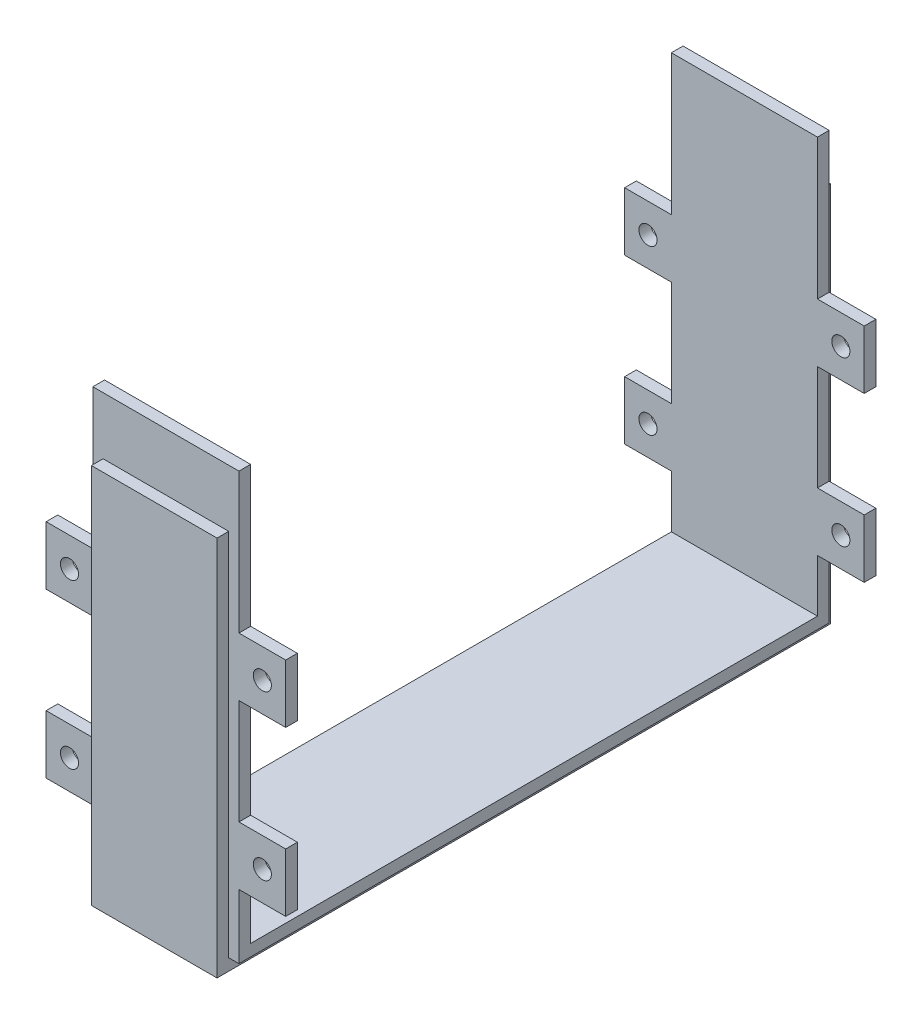
from build123d import *

# Parameters (mm, degrees)
SKETCH1_W           = 105
SKETCH1_H           = 4
SKETCH1_W_2         = 2
SKETCH1_H_2         = 9.8
BOSS_EXTRUDE1_DEPTH = 12.5
SKETCH2_W           = 8
SKETCH2_H           = 10
SKETCH2_R           = 1.55
BOSS_EXTRUDE2_DEPTH = 2
SKETCH4_W           = 8
SKETCH4_H           = 10
SKETCH4_R           = 1.55
BOSS_EXTRUDE3_DEPTH = 2
SKETCH5_W           = 101
SKETCH5_H           = 2
CUT_EXTRUDE1_DEPTH  = 1.75
SKETCH6_W           = 101
SKETCH6_H           = 2
CUT_EXTRUDE2_DEPTH  = 1.75


with BuildPart() as part:
    # Sketch1 → Boss-Extrude1 (new body, symmetric)
    with BuildSketch(Plane(origin=(0, 0, 0), x_dir=(0, 0, -1), z_dir=(1, 0, 0))):
        Rectangle(SKETCH1_W, SKETCH1_H)
        Polygon((-52.5, 63.2), (-52.5, 2), (-48.5, 2), (-48.5, 63.2), (-50.5, 63.2), align=None)
        Polygon((48.5, 63.2), (48.5, 2), (52.5, 2), (52.5, 63.2), (50.5, 63.2), align=None)
        with Locations((-49.5, 68.1)):
            Rectangle(SKETCH1_W_2, SKETCH1_H_2)
        with Locations((49.5, 68.1)):
            Rectangle(SKETCH1_W_2, SKETCH1_H_2)
    extrude(amount=BOSS_EXTRUDE1_DEPTH, both=True)

    # Sketch2 → Boss-Extrude2 (add)
    with BuildSketch(Plane.XY.offset(-48.5)):
        with Locations((-16.5, 16)):
            Rectangle(SKETCH2_W, SKETCH2_H)
        with Locations((-16.5, 16)):
            Circle(SKETCH2_R, mode=Mode.SUBTRACT)
        with Locations((-16.5, 44)):
            Rectangle(SKETCH2_W, SKETCH2_H)
        with Locations((-16.5, 44)):
            Circle(SKETCH2_R, mode=Mode.SUBTRACT)
        with Locations((16.5, 16)):
            Rectangle(SKETCH2_W, SKETCH2_H)
        with Locations((16.5, 16)):
            Circle(SKETCH2_R, mode=Mode.SUBTRACT)
        with Locations((16.5, 44)):
            Rectangle(SKETCH2_W, SKETCH2_H)
        with Locations((16.5, 44)):
            Circle(SKETCH2_R, mode=Mode.SUBTRACT)
    extrude(amount=-BOSS_EXTRUDE2_DEPTH)

    # Sketch4 → Boss-Extrude3 (add)
    with BuildSketch(Plane(origin=(0, 0, 48.5), x_dir=(-1, 0, 0), z_dir=(0, 0, -1))):
        with Locations((-16.5, 16)):
            Rectangle(SKETCH4_W, SKETCH4_H)
        with Locations((-16.5, 16)):
            Circle(SKETCH4_R, mode=Mode.SUBTRACT)
        with Locations((-16.5, 44)):
            Rectangle(SKETCH4_W, SKETCH4_H)
        with Locations((-16.5, 44)):
            Circle(SKETCH4_R, mode=Mode.SUBTRACT)
        with Locations((16.5, 16)):
            Rectangle(SKETCH4_W, SKETCH4_H)
        with Locations((16.5, 16)):
            Circle(SKETCH4_R, mode=Mode.SUBTRACT)
        with Locations((16.5, 44)):
            Rectangle(SKETCH4_W, SKETCH4_H)
        with Locations((16.5, 44)):
            Circle(SKETCH4_R, mode=Mode.SUBTRACT)
    extrude(amount=-BOSS_EXTRUDE3_DEPTH)

    # Sketch5 → Cut-Extrude1 (cut)
    with BuildSketch(Plane.ZY.offset(12.5)):
        Polygon((-50.5, 63.2), (-52.5, 63.2), (-52.5, -2), (-50.5, -2), (-50.5, 0), (-50.5, 11), (-50.5, 21), (-50.5, 39), (-50.5, 49), align=None)
        with Locations((0, -1)):
            Rectangle(SKETCH5_W, SKETCH5_H)
        Polygon((50.5, 0), (50.5, -2), (52.5, -2), (52.5, 63.2), (50.5, 63.2), (50.5, 49), (50.5, 39), (50.5, 21), (50.5, 11), align=None)
    extrude(amount=-CUT_EXTRUDE1_DEPTH, mode=Mode.SUBTRACT)

    # Sketch6 → Cut-Extrude2 (cut)
    with BuildSketch(Plane(origin=(12.5, 0, 0), x_dir=(0, 0, -1), z_dir=(1, 0, 0))):
        Polygon((-50.5, 0), (-50.5, 63.2), (-52.5, 63.2), (-52.5, -2), (-50.5, -2), align=None)
        with Locations((0, -1)):
            Rectangle(SKETCH6_W, SKETCH6_H)
        Polygon((50.5, 63.2), (50.5, 0), (50.5, -2), (52.5, -2), (52.5, 63.2), align=None)
    extrude(amount=-CUT_EXTRUDE2_DEPTH, mode=Mode.SUBTRACT)


solid = part.part
